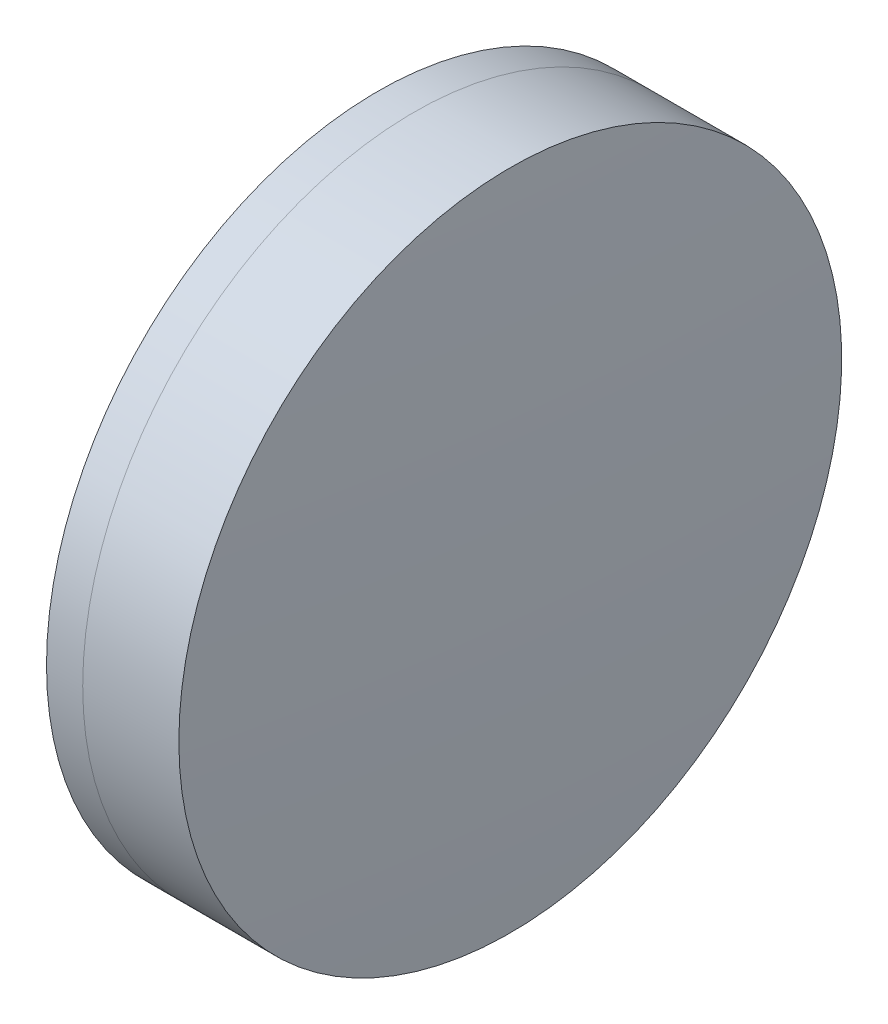
from build123d import *


with BuildPart() as part:
    # 草图1 one side → 旋转1 (revolve)
    with BuildSketch(Plane(origin=(0, 0, 0), x_dir=(1, 0, 0), z_dir=(0, 1, 0)), mode=Mode.PRIVATE) as revolve_1_sk:
        with BuildLine():
            ThreePointArc((561.209893851, 25.4), (559.389275513, 12.757955033), (558.780559274, 0))
            Line((558.780559274, 0), (566.980559274, 0))
            ThreePointArc((566.980559274, 0), (566.229198447, 12.787988956), (563.985455583, 25.4))
            Line((563.985455583, 25.4), (561.209893851, 25.4))
        make_face()
    revolve(revolve_1_sk.sketch.rotate(Axis((124.523309526, 0, 0), (1, 0, 0)), 180), axis=Axis((124.523309526, 0, 0), (1, 0, 0)))  # turned: the seam where the file's is


with BuildPart() as body_2:
    # 草图2 one side → 旋转3 (revolve)
    with BuildSketch(Plane(origin=(0, 0, 0), x_dir=(1, 0, 0), z_dir=(0, 1, 0)), mode=Mode.PRIVATE) as revolve_3_sk:
        with BuildLine():
            Line((571.354052568, 25.4), (563.985455583, 25.4))
            ThreePointArc((563.985455583, 25.4), (566.229198447, 12.787988956), (566.980559274, 0))
            Line((566.980559274, 0), (571.980559274, 0))
            ThreePointArc((571.980559274, 0), (571.823908782, 12.703862706), (571.354052568, 25.4))
        make_face()
    revolve(revolve_3_sk.sketch.rotate(Axis((-0.551919993, 0, 0), (1, 0, 0)), 180), axis=Axis((-0.551919993, 0, 0), (1, 0, 0)))  # turned: the seam where the file's is


solid = Compound([part.part, body_2.part])
